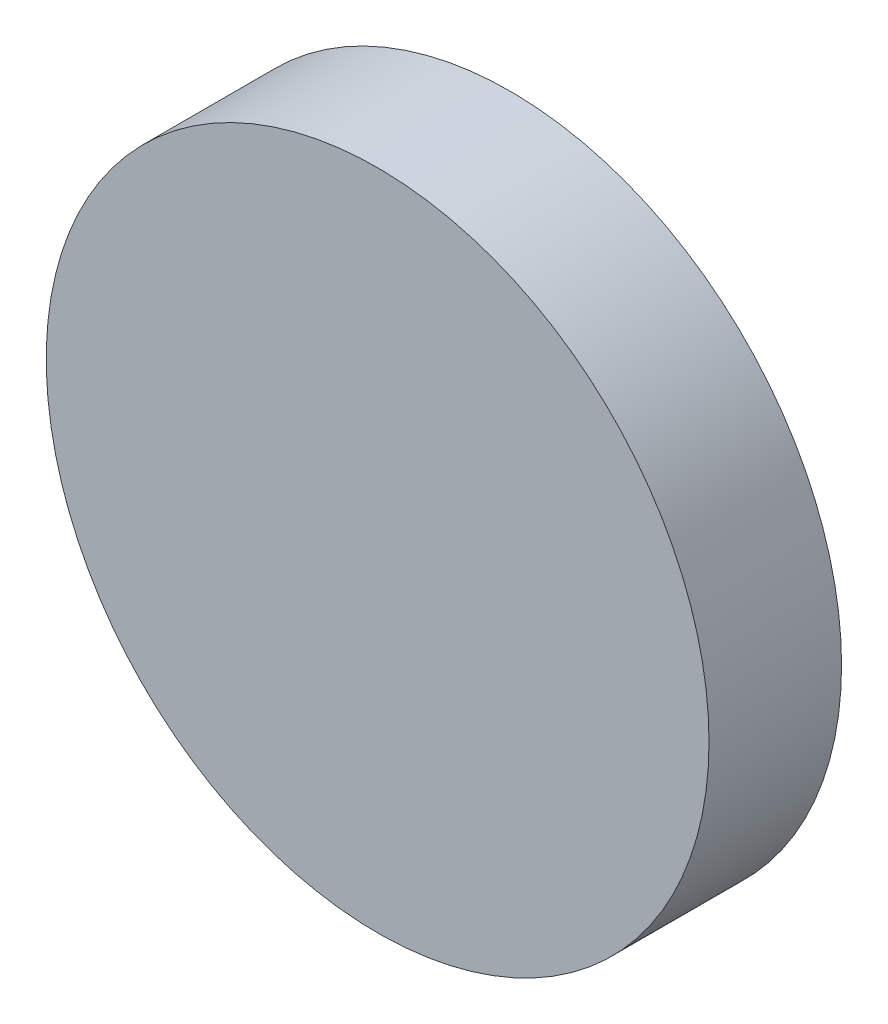
from build123d import *

# Parameters (mm, degrees)
SKETCH_1_R      = 12.5
EXTRUDE_1_DEPTH = 5


with BuildPart() as part:
    # 草图1 → 凸台-拉伸1 (new body)
    with BuildSketch(Plane.XY):
        Circle(SKETCH_1_R)
    extrude(amount=EXTRUDE_1_DEPTH)


solid = part.part
